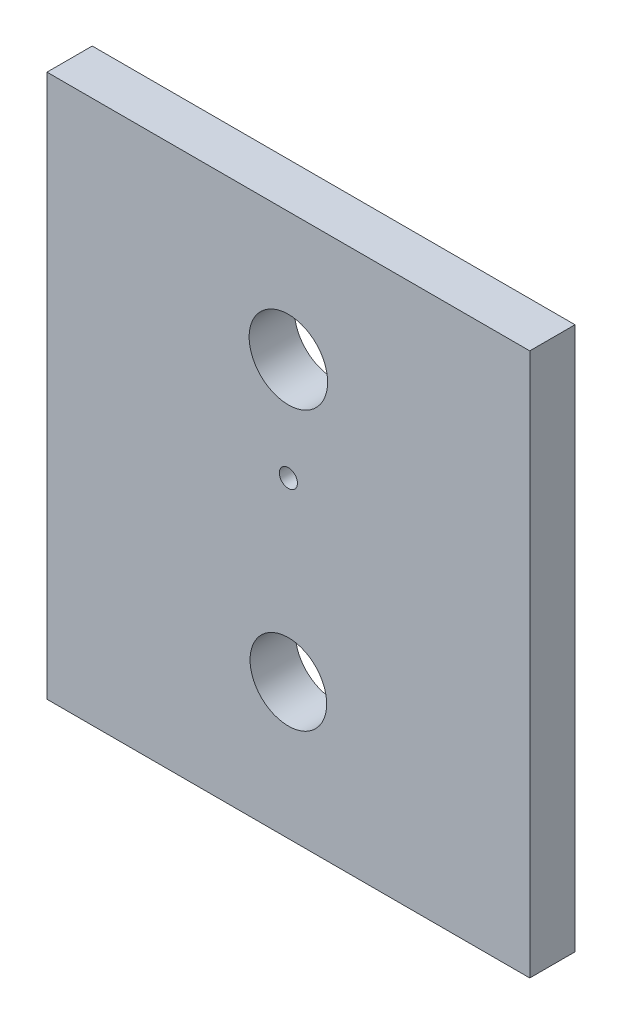
from build123d import *

# Parameters (mm, degrees)
SKETCH2_W                  = 160
SKETCH2_H                  = 180
BOSS_EXTRUDE1_DEPTH        = 15
F_20_0_20_DIAMETER_HOLE1_D = 26.01
F_6_0MM_DOWEL_HOLE1_D      = 6
F_6_0MM_DOWEL_HOLE1_DEPTH  = 40
F_6_0MM_DOWEL_HOLE1_TIP    = 1.802581857
SKETCH10_R                 = 12.7
CUT_EXTRUDE1_DEPTH         = 16


with BuildPart() as part:
    # Sketch2 → Boss-Extrude1 (new body)
    with BuildSketch(Plane.XY):
        with Locations((0, -5)):
            Rectangle(SKETCH2_W, SKETCH2_H)
    extrude(amount=BOSS_EXTRUDE1_DEPTH)

    # Ø20.0 (20) Diameter Hole1 (through all)
    with Locations(Plane.XY.offset(15)):
        with Locations((0, 42.5)):
            Hole(F_20_0_20_DIAMETER_HOLE1_D / 2)

    # Ø6.0mm Dowel Hole1
    with Locations(Plane.XY.offset(15)):
        with Locations((0, 8.5)):
            Hole(F_6_0MM_DOWEL_HOLE1_D / 2, depth=F_6_0MM_DOWEL_HOLE1_DEPTH)
            with Locations((0, 0, -(F_6_0MM_DOWEL_HOLE1_DEPTH + F_6_0MM_DOWEL_HOLE1_TIP / 2))):  # 118° drill point
                Cone(0, F_6_0MM_DOWEL_HOLE1_D / 2, F_6_0MM_DOWEL_HOLE1_TIP, mode=Mode.SUBTRACT)

    # Sketch10 → Cut-Extrude1 (cut, through all)
    with BuildSketch(Plane.XY.offset(15)):
        with Locations((0, -50)):
            Circle(SKETCH10_R)
    extrude(amount=-CUT_EXTRUDE1_DEPTH, mode=Mode.SUBTRACT)


solid = part.part
